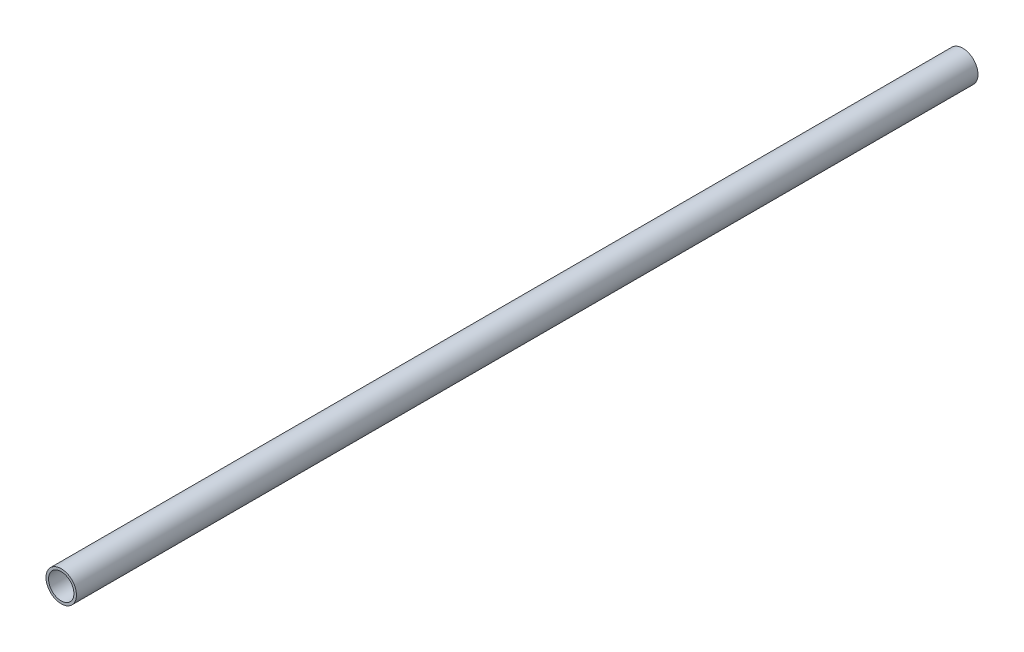
from build123d import *

# Parameters (mm, degrees)
SKETCH_1_R          = 24
EXTRUDE_1_DEPTH     = 1420
SKETCH_2_R          = 20
CUT_EXTRUDE_1_DEPTH = 1421


with BuildPart() as part:
    # Эскиз1 → Бобышка-Вытянуть1 (new body)
    with BuildSketch(Plane.XY):
        Circle(SKETCH_1_R)
    extrude(amount=EXTRUDE_1_DEPTH)

    # Эскиз2 → Вырез-Вытянуть1 (cut, through all)
    with BuildSketch(Plane(origin=(0, 0, 0), x_dir=(-1, 0, 0), z_dir=(0, 0, -1))):
        Circle(SKETCH_2_R)
    extrude(amount=-CUT_EXTRUDE_1_DEPTH, mode=Mode.SUBTRACT)


solid = part.part
